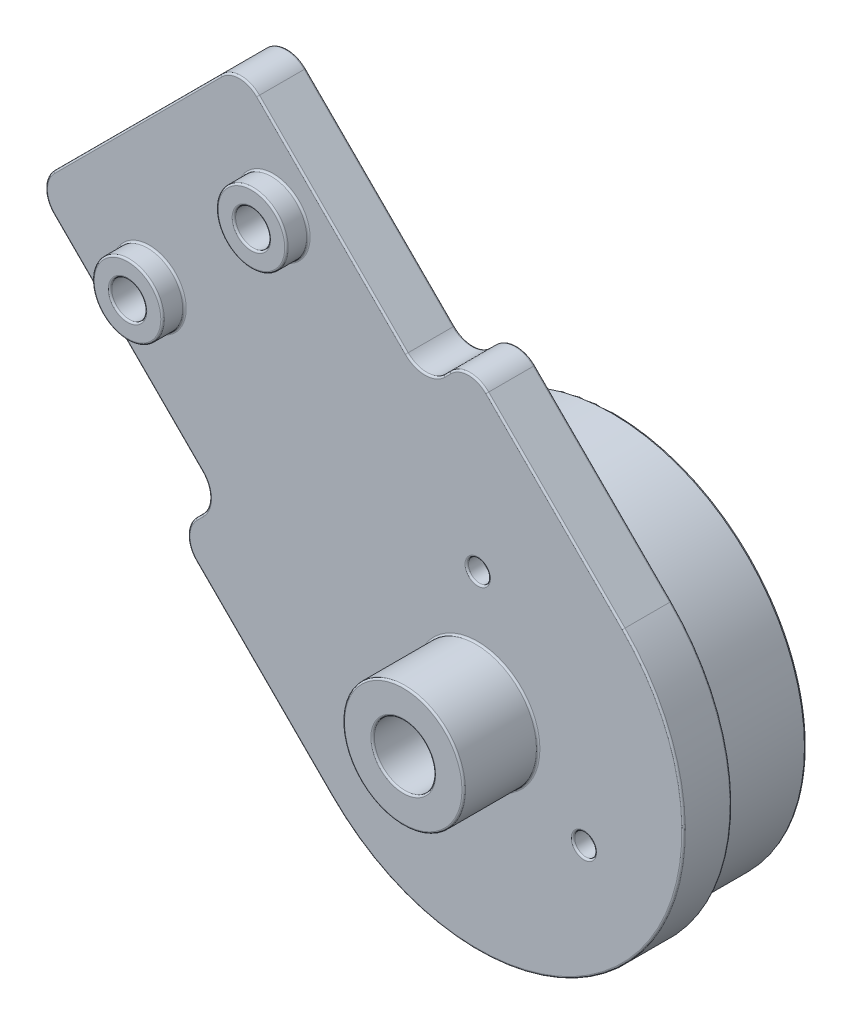
from build123d import *

# Parameters (mm, degrees)
SKETCH3_R           = 10
BOSS_EXTRUDE1_DEPTH = 2.75
SKETCH5_R           = 1
CUT_EXTRUDE1_DEPTH  = 2.75
SKETCH9_R           = 10
BOSS_EXTRUDE3_DEPTH = 1
SKETCH10_R          = 11
SKETCH10_R_2        = 10
BOSS_EXTRUDE4_DEPTH = 5
FILLET1_R           = 1.5
SKETCH11_R          = 2
SKETCH11_R_2        = 1
BOSS_EXTRUDE5_DEPTH = 1.25
SKETCH12_R          = 1.75
CUT_EXTRUDE2_DEPTH  = 1
SKETCH13_R          = 3.45
SKETCH13_R_2        = 1.75
BOSS_EXTRUDE6_DEPTH = 4.25
SKETCH14_R          = 0.625
CUT_EXTRUDE3_DEPTH  = 1
FILLET2_R           = 0.1


with BuildPart() as part:
    # Sketch3 → Boss-Extrude1 (new body)
    with BuildSketch(Plane.XY):
        with BuildLine():
            Line((86.388194462, 25.279067427), (74.720932573, 13.611805538))
            Line((74.720932573, 13.611805538), (85.32753429, 3.00520382))
            Line((85.32753429, 3.00520382), (82.852660556, 0.530330086))
            Line((82.852660556, 0.530330086), (91.691495321, -8.308504679))
            ThreePointArc((91.691495321, -8.308504679), (108.308504679, -8.308504679), (108.308504679, 8.308504679))
            Line((108.308504679, 8.308504679), (99.469669914, 17.147339444))
            Line((99.469669914, 17.147339444), (96.99479618, 14.67246571))
            Line((96.99479618, 14.67246571), (86.388194462, 25.279067427))
        make_face()
        with Locations((100, 0)):
            Circle(SKETCH3_R, mode=Mode.SUBTRACT)
    extrude(amount=BOSS_EXTRUDE1_DEPTH)

    # Sketch5 → Cut-Extrude1 (cut)
    with BuildSketch(Plane.XY):
        with Locations((81.261670351, 11.667261837)):
            Circle(SKETCH5_R)
        with Locations((88.332738163, 18.738329649)):
            Circle(SKETCH5_R)
    extrude(amount=CUT_EXTRUDE1_DEPTH, mode=Mode.SUBTRACT)

    # Sketch9 → Boss-Extrude3 (add)
    with BuildSketch(Plane.XY.offset(2.75)):
        with Locations((100, 0)):
            Circle(SKETCH9_R)
    extrude(amount=-BOSS_EXTRUDE3_DEPTH)

    # Sketch10 → Boss-Extrude4 (add)
    with BuildSketch(Plane(origin=(0, 0, 0), x_dir=(-1, 0, 0), z_dir=(0, 0, -1))):
        with Locations((-100, 0)):
            Circle(SKETCH10_R)
        with Locations((-100, 0)):
            Circle(SKETCH10_R_2, mode=Mode.SUBTRACT)
    extrude(amount=BOSS_EXTRUDE4_DEPTH)

    # Fillet1
    fillet1_edges = [part.edges().sort_by_distance(p)[0] for p in [
        (96.99479618, 14.67246571, 1.375),
        (99.469669914, 17.147339444, 1.375),
        (82.852660556, 0.530330086, 1.375),
        (85.32753429, 3.00520382, 1.375),
        (74.720932573, 13.611805538, 1.375),
        (86.388194462, 25.279067427, 1.375),
    ]]
    fillet(fillet1_edges, radius=FILLET1_R)

    # Sketch11 → Boss-Extrude5 (add)
    with BuildSketch(Plane.XY.offset(2.75)):
        with Locations((88.332738163, 18.738329649)):
            Circle(SKETCH11_R)
        with Locations((88.332738163, 18.738329649)):
            Circle(SKETCH11_R_2, mode=Mode.SUBTRACT)
        with Locations((81.261670351, 11.667261837)):
            Circle(SKETCH11_R)
        with Locations((81.261670351, 11.667261837)):
            Circle(SKETCH11_R_2, mode=Mode.SUBTRACT)
    extrude(amount=BOSS_EXTRUDE5_DEPTH)

    # Sketch12 → Cut-Extrude2 (cut)
    with BuildSketch(Plane.XY.offset(2.75)):
        with Locations((100, 0)):
            Circle(SKETCH12_R)
    extrude(amount=-CUT_EXTRUDE2_DEPTH, mode=Mode.SUBTRACT)

    # Sketch13 → Boss-Extrude6 (add)
    with BuildSketch(Plane.XY.offset(2.75)):
        with Locations((100, 0)):
            Circle(SKETCH13_R)
        with Locations((100, 0)):
            Circle(SKETCH13_R_2, mode=Mode.SUBTRACT)
    extrude(amount=BOSS_EXTRUDE6_DEPTH)

    # Sketch14 → Cut-Extrude3 (cut)
    with BuildSketch(Plane.XY.offset(2.75)):
        with Locations((100, 7)):
            Circle(SKETCH14_R)
        with Locations((106.062177826, -3.5)):
            Circle(SKETCH14_R)
        with Locations((93.937822174, -3.5)):
            Circle(SKETCH14_R)
    extrude(amount=-CUT_EXTRUDE3_DEPTH, mode=Mode.SUBTRACT)

    # Fillet2
    fillet2_edges = [part.edges().sort_by_distance(p)[0] for p in [
        (98.25, 0, 1.75),
        (96.55, 0, 7),
        (96.55, 0, 2.75),
        (98.25, 0, 7),
        (99.375, 7, 2.75),
        (99.375, 7, 1.75),
        (105.437177826, -3.5, 2.75),
        (105.437177826, -3.5, 1.75),
        (93.312822174, -3.5, 2.75),
        (93.312822174, -3.5, 1.75),
        (108.308504679, -8.308504679, 2.75),
        (104.419417382, 12.197591975, 2.75),
        (80.261670351, 11.667261837, 0),
        (87.332738163, 18.738329649, 0),
        (90, 0, 1.75),
        (111, 0, 0),
        (111, 0, -5),
        (110, 0, -5),
        (91.691495321, 19.975766569, 0),
        (91.691495321, 19.975766569, 2.75),
        (98.232233047, 15.909902577, 0),
        (98.232233047, 15.909902577, 2.75),
        (87.802408025, -4.419417382, 0),
        (84.090097423, 1.767766953, 0),
        (80.024233431, 8.308504679, 0),
        (80.554563517, 19.445436483, 0),
        (86.388194462, 24.657747084, 0),
        (75.342252916, 13.611805538, 0),
        (83.4739809, 0.530330086, 0),
        (99.469669914, 16.5260191, 0),
        (80.554563517, 19.445436483, 2.75),
        (80.024233431, 8.308504679, 2.75),
        (84.090097423, 1.767766953, 2.75),
        (87.802408025, -4.419417382, 2.75),
        (86.388194462, 24.657747084, 2.75),
        (75.342252916, 13.611805538, 2.75),
        (83.4739809, 0.530330086, 2.75),
        (99.469669914, 16.5260191, 2.75),
        (96.99479618, 15.293786053, 0),
        (96.99479618, 15.293786053, 2.75),
        (84.706213947, 3.00520382, 0),
        (84.706213947, 3.00520382, 2.75),
        (104.419417382, 12.197591975, 0),
        (86.332738163, 18.738329649, 4),
        (86.332738163, 18.738329649, 2.75),
        (87.332738163, 18.738329649, 4),
        (108.308504679, -8.308504679, 0),
        (79.261670351, 11.667261837, 4),
        (79.261670351, 11.667261837, 2.75),
        (80.261670351, 11.667261837, 4),
    ]]
    fillet(fillet2_edges, radius=FILLET2_R)


solid = part.part
